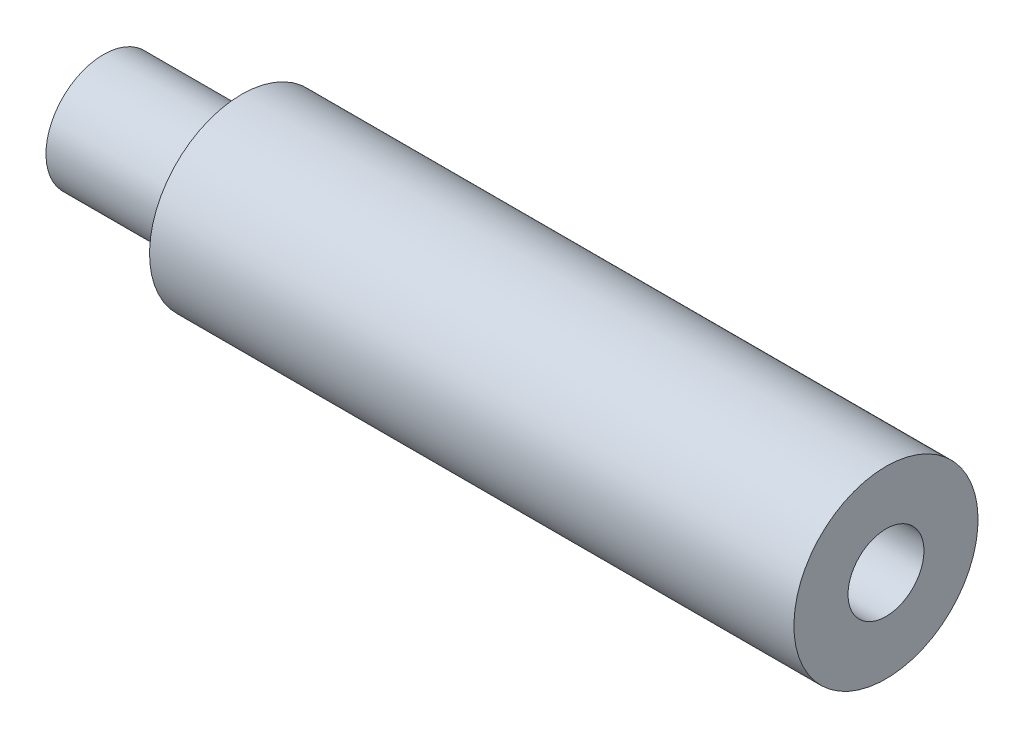
from build123d import *

# Parameters (mm, degrees)
TROU_TARAUD_M41_D     = 3.3
TROU_TARAUD_M41_DEPTH = 25
TROU_TARAUD_M41_TIP   = 0.991420021


with BuildPart() as part:
    # Esquisse1 → Révolution1 (revolve)
    with BuildSketch(Plane.XY):
        Polygon((0, 0), (0, 2.5), (6, 2.5), (6, 4), (34, 4), (34, 0), align=None)
    revolve(axis=Axis((34, 0, 0), (-1, 0, 0)))

    # Trou taraudé M41
    with Locations(Plane(origin=(34, -0.282646885, -1.42571366), x_dir=(0, 0, 1), z_dir=(1, 0, 0))):
        with Locations((1.42571366, -0.282646885)):
            Hole(TROU_TARAUD_M41_D / 2, depth=TROU_TARAUD_M41_DEPTH)
            with Locations((0, 0, -(TROU_TARAUD_M41_DEPTH + TROU_TARAUD_M41_TIP / 2))):  # 118° drill point
                Cone(0, TROU_TARAUD_M41_D / 2, TROU_TARAUD_M41_TIP, mode=Mode.SUBTRACT)


solid = part.part
